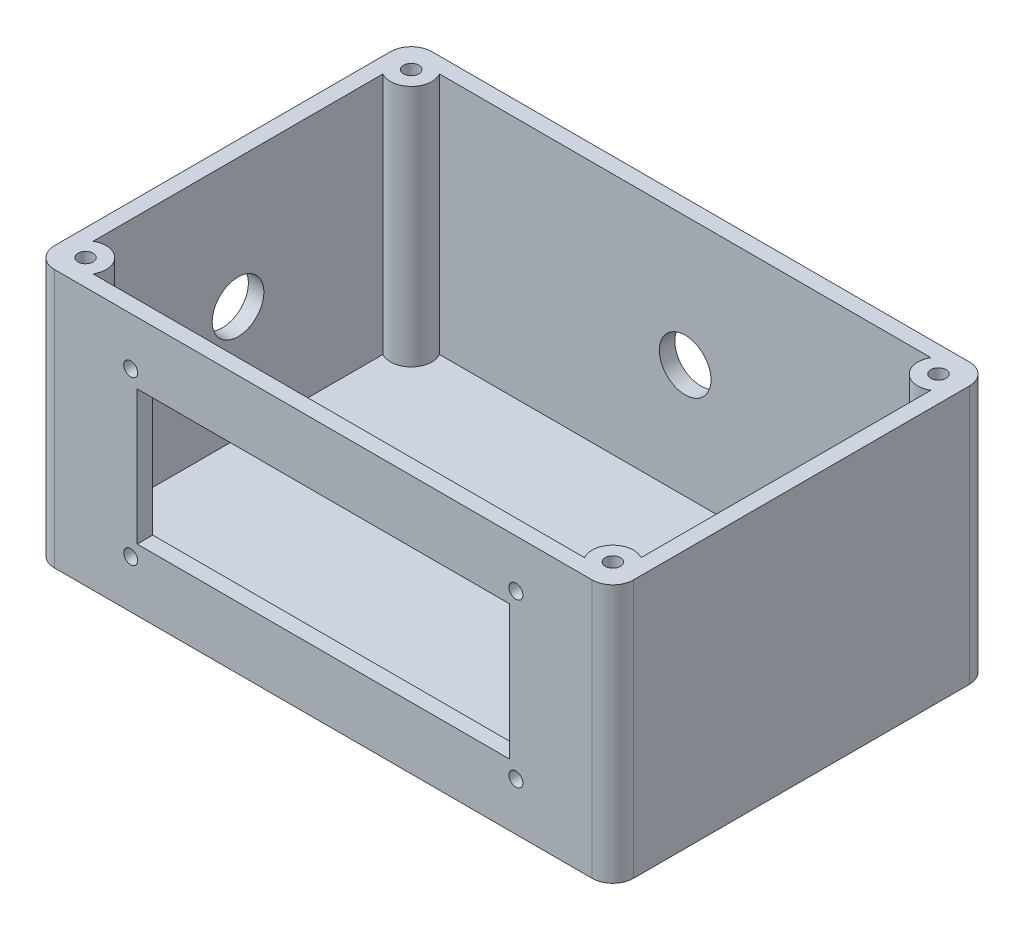
from build123d import *

# Parameters (mm, degrees)
SKETCH2_W           = 112
SKETCH2_H           = 73
BOSS_EXTRUDE1_DEPTH = 50
SHELL3_T            = -3
SKETCH5_R           = 4
BOSS_EXTRUDE2_DEPTH = 47.5
CUT_EXTRUDE1_REACH  = 75
SKETCH3_W           = 72
SKETCH3_H           = 26
SKETCH6_R           = 1.47
CUT_EXTRUDE2_DEPTH  = 10
FILLET1_R           = 4
CUT_EXTRUDE3_REACH  = 75
SKETCH7_R           = 1.35
CUT_EXTRUDE4_REACH  = 75
SKETCH8_R           = 5
CUT_EXTRUDE5_REACH  = 114
SKETCH9_R           = 5


with BuildPart() as part:
    # Sketch2 → Boss-Extrude1 (new body)
    with BuildSketch(Plane(origin=(0, 0, 0), x_dir=(1, 0, 0), z_dir=(0, 1, 0))):
        Rectangle(SKETCH2_W, SKETCH2_H)
    extrude(amount=BOSS_EXTRUDE1_DEPTH)

    # Shell3
    shell3_openings = [part.faces().sort_by_distance(p)[0] for p in [
        (0, 50, 0),
    ]]
    offset(amount=SHELL3_T, openings=shell3_openings, kind=Kind.INTERSECTION)

    # Sketch5 → Boss-Extrude2 (add)
    with BuildSketch(Plane(origin=(0, 2.5, 0), x_dir=(1, 0, 0), z_dir=(0, 1, 0))):
        with Locations((-51, 31.5)):
            Circle(SKETCH5_R)
        with Locations((-51, -31.5)):
            Circle(SKETCH5_R)
        with Locations((51, 31.5)):
            Circle(SKETCH5_R)
        with Locations((51, -31.5)):
            Circle(SKETCH5_R)
    extrude(amount=BOSS_EXTRUDE2_DEPTH)

    # Sketch3 → Cut-Extrude1 (cut, up to next)
    with BuildSketch(Plane.XY.offset(36.5), mode=Mode.PRIVATE) as cut_extrude1_sk1:
        with Locations((0, 25)):
            Rectangle(SKETCH3_W, SKETCH3_H)
    cut_extrude1_tool1 = extrude(cut_extrude1_sk1.sketch, amount=-CUT_EXTRUDE1_REACH, mode=Mode.PRIVATE) & part.part
    add(cut_extrude1_tool1.solids().sort_by_distance((0, 25, 36.5))[0], mode=Mode.SUBTRACT)

    # Sketch6 → Cut-Extrude2 (cut)
    with BuildSketch(Plane(origin=(0, 50, 0), x_dir=(1, 0, 0), z_dir=(0, 1, 0))):
        with Locations((51, 31.5)):
            Circle(SKETCH6_R)
        with Locations((51, -31.5)):
            Circle(SKETCH6_R)
        with Locations((-51, -31.5)):
            Circle(SKETCH6_R)
        with Locations((-51, 31.5)):
            Circle(SKETCH6_R)
    extrude(amount=-CUT_EXTRUDE2_DEPTH, mode=Mode.SUBTRACT)

    # Fillet1
    fillet1_edges = [part.edges().sort_by_distance(p)[0] for p in [
        (56, 25, 36.5),
        (-56, 25, 36.5),
        (-56, 25, -36.5),
        (56, 25, -36.5),
    ]]
    fillet(fillet1_edges, radius=FILLET1_R)

    # Sketch7 → Cut-Extrude3 (cut, up to next)
    with BuildSketch(Plane.XY.offset(36.5), mode=Mode.PRIVATE) as cut_extrude3_sk1:
        with Locations((-37.26, 40.74)):
            Circle(SKETCH7_R)
    cut_extrude3_tool1 = extrude(cut_extrude3_sk1.sketch, amount=-CUT_EXTRUDE3_REACH, mode=Mode.PRIVATE) & part.part
    add(cut_extrude3_tool1.solids().sort_by_distance((-37.26, 40.74, 36.5))[0], mode=Mode.SUBTRACT)
    # Sketch7 → Cut-Extrude3 (cut, up to next)
    with BuildSketch(Plane.XY.offset(36.5), mode=Mode.PRIVATE) as cut_extrude3_sk2:
        with Locations((-37.26, 9.26)):
            Circle(SKETCH7_R)
    cut_extrude3_tool2 = extrude(cut_extrude3_sk2.sketch, amount=-CUT_EXTRUDE3_REACH, mode=Mode.PRIVATE) & part.part
    add(cut_extrude3_tool2.solids().sort_by_distance((-37.26, 9.26, 36.5))[0], mode=Mode.SUBTRACT)
    # Sketch7 → Cut-Extrude3 (cut, up to next)
    with BuildSketch(Plane.XY.offset(36.5), mode=Mode.PRIVATE) as cut_extrude3_sk3:
        with Locations((37.26, 40.74)):
            Circle(SKETCH7_R)
    cut_extrude3_tool3 = extrude(cut_extrude3_sk3.sketch, amount=-CUT_EXTRUDE3_REACH, mode=Mode.PRIVATE) & part.part
    add(cut_extrude3_tool3.solids().sort_by_distance((37.26, 40.74, 36.5))[0], mode=Mode.SUBTRACT)
    # Sketch7 → Cut-Extrude3 (cut, up to next)
    with BuildSketch(Plane.XY.offset(36.5), mode=Mode.PRIVATE) as cut_extrude3_sk4:
        with Locations((37.26, 9.26)):
            Circle(SKETCH7_R)
    cut_extrude3_tool4 = extrude(cut_extrude3_sk4.sketch, amount=-CUT_EXTRUDE3_REACH, mode=Mode.PRIVATE) & part.part
    add(cut_extrude3_tool4.solids().sort_by_distance((37.26, 9.26, 36.5))[0], mode=Mode.SUBTRACT)

    # Sketch8 → Cut-Extrude4 (cut, up to next)
    with BuildSketch(Plane(origin=(0, 0, -36.5), x_dir=(-1, 0, 0), z_dir=(0, 0, -1)), mode=Mode.PRIVATE) as cut_extrude4_sk1:
        with Locations((0, 25)):
            Circle(SKETCH8_R)
    cut_extrude4_tool1 = extrude(cut_extrude4_sk1.sketch, amount=-CUT_EXTRUDE4_REACH, mode=Mode.PRIVATE) & part.part
    add(cut_extrude4_tool1.solids().sort_by_distance((0, 25, -36.5))[0], mode=Mode.SUBTRACT)

    # Sketch9 → Cut-Extrude5 (cut, up to next)
    with BuildSketch(Plane.ZY.offset(56), mode=Mode.PRIVATE) as cut_extrude5_sk1:
        with Locations((0, 25)):
            Circle(SKETCH9_R)
    cut_extrude5_tool1 = extrude(cut_extrude5_sk1.sketch, amount=-CUT_EXTRUDE5_REACH, mode=Mode.PRIVATE) & part.part
    add(cut_extrude5_tool1.solids().sort_by_distance((-56, 25, 0))[0], mode=Mode.SUBTRACT)


solid = part.part
